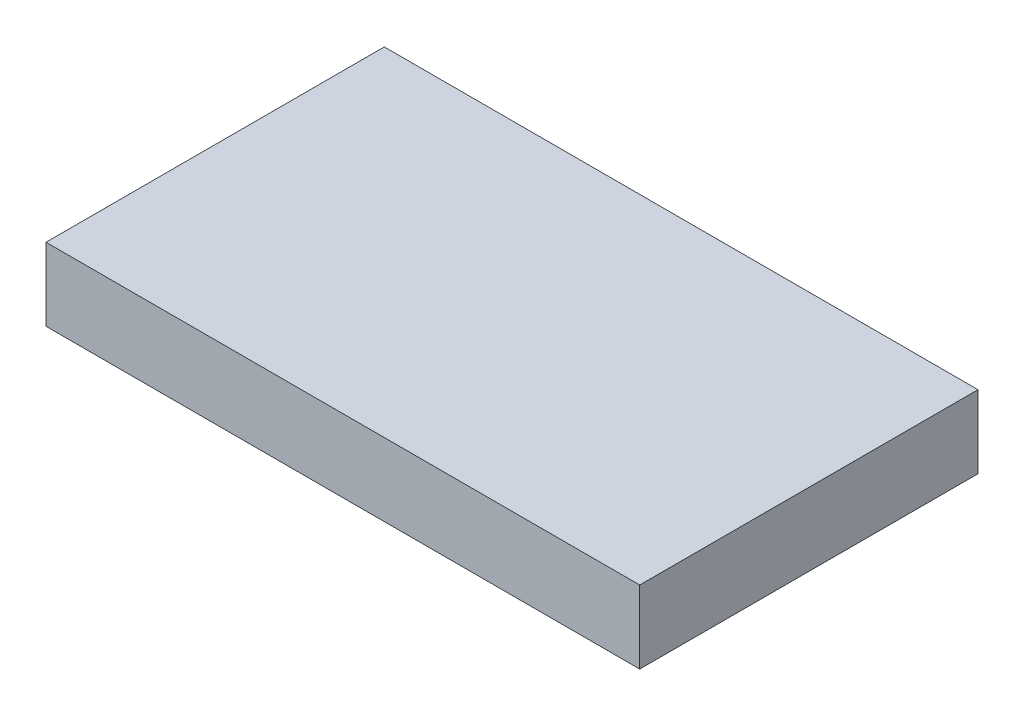
from build123d import *

# Parameters (mm, degrees)
SKETCH1_W           = 53
SKETCH1_H           = 30.2
BOSS_EXTRUDE1_DEPTH = 6.5


with BuildPart() as part:
    # Sketch1 → Boss-Extrude1 (new body)
    with BuildSketch(Plane(origin=(0, 0, 0), x_dir=(1, 0, 0), z_dir=(0, 1, 0))):
        Rectangle(SKETCH1_W, SKETCH1_H)
    extrude(amount=BOSS_EXTRUDE1_DEPTH)


solid = part.part
